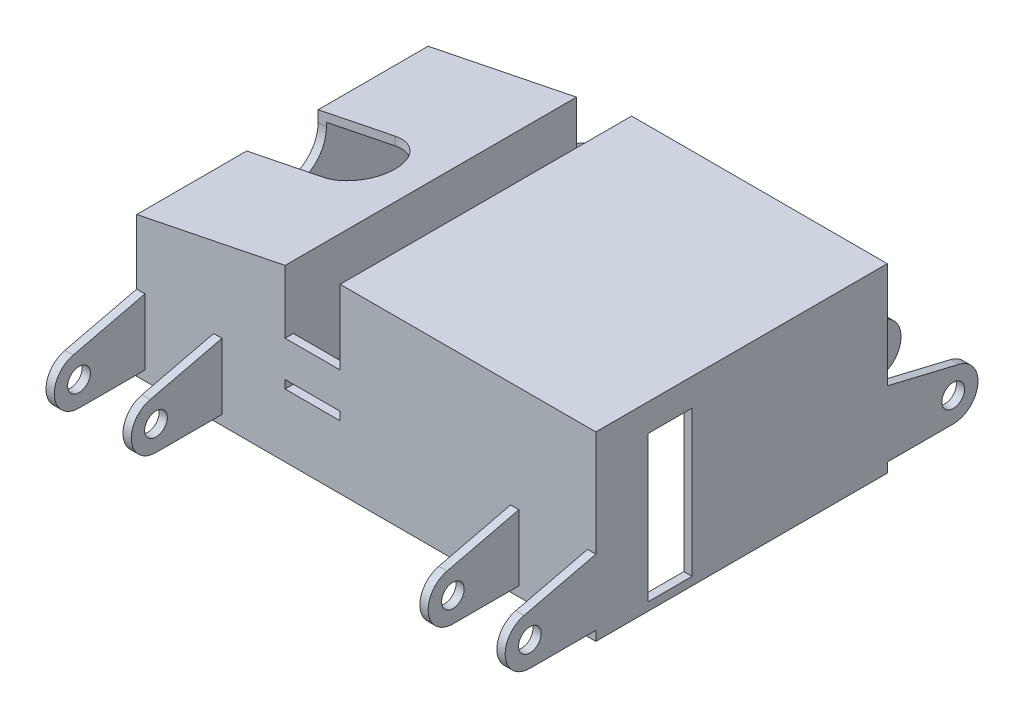
from build123d import *

# Parameters (mm, degrees)
BOSS_EXTRUDE1_DEPTH = 100
BOSS_EXTRUDE2_DEPTH = 3
SKETCH4_W           = 71
SKETCH4_H           = 3
BOSS_EXTRUDE3_DEPTH = 20
BOSS_EXTRUDE4_REACH = 48
SKETCH6_W           = 48
SKETCH6_H           = 3
CUT_EXTRUDE1_DEPTH  = 3
SKETCH8_R           = 2.5
SKETCH8_R_2         = 1.7
CUT_EXTRUDE2_DEPTH  = 3
SKETCH9_R           = 3.2
SKETCH9_R_2         = 2.5
CUT_EXTRUDE3_DEPTH  = 3
SKETCH10_R          = 1.7
CUT_EXTRUDE4_DEPTH  = 3
SKETCH13_R          = 2.5
CUT_EXTRUDE6_DEPTH  = 3
BOSS_EXTRUDE5_DEPTH = 3
BOSS_EXTRUDE6_DEPTH = 5
CUT_EXTRUDE8_DEPTH  = 18
SKETCH20_W          = 20.000898322
SKETCH20_H          = 3
CUT_EXTRUDE9_DEPTH  = 3
SKETCH21_W          = 20.000898322
SKETCH21_H          = 3
CUT_EXTRUDE10_DEPTH = 3
SKETCH22_R          = 4.125
BOSS_EXTRUDE7_DEPTH = 3
LPATTERN1_COUNT     = 2
LPATTERN1_PITCH     = 28
LPATTERN2_COUNT     = 2
LPATTERN2_PITCH     = 164
LPATTERN3_COUNT     = 2
LPATTERN3_PITCH     = 136
SKETCH23_W          = 16
SKETCH23_H          = 53
CUT_EXTRUDE11_DEPTH = 3


with BuildPart() as part:
    # Sketch1 → Boss-Extrude1 (new body)
    with BuildSketch(Plane.XY):
        Polygon((0, 60), (0, -3), (3, -3), (3, 63), (-90, 63), (-90, 20), (-110.000898322, 20), (-110.033128512, 58.939230707), (-164, 48), (-164, -3), (-161, -3), (-161, 45.547095944), (-113, 55.276825673), (-113, 17), (-90, 17), (-90, -3), (-87, -3), (-87, 60), align=None)
    extrude(amount=BOSS_EXTRUDE1_DEPTH)

    # Sketch2 → Boss-Extrude2 (add)
    with BuildSketch(Plane.XY.offset(100)):
        Polygon((-164, -3), (3, -3), (3, 63), (-90, 63), (-90, 35.999994519), (-110.014141595, 35.999994519), (-110.033128512, 58.939230707), (-164, 48), align=None)
    extrude(amount=BOSS_EXTRUDE2_DEPTH)

    # Sketch4 → Boss-Extrude3 (add)
    with BuildSketch(Plane.XZ.offset(3)):
        with Locations((-125.5, 67.5)):
            Rectangle(SKETCH4_W, SKETCH4_H)
    extrude(amount=-BOSS_EXTRUDE3_DEPTH)

    # Boss-Extrude4: up to this face of the body (flat: up to its plane)
    boss_extrude4_end = Plane(part.part.faces().sort_by_distance((-137, 50.411960808, 50))[0])
    # Sketch6 → Boss-Extrude4 (add, up to the picked face)
    with BuildSketch(Plane(origin=(0, 17, 0), x_dir=(1, 0, 0), z_dir=(0, 1, 0)), mode=Mode.PRIVATE) as boss_extrude4_sk1:
        with Locations((-137, -67.5)):
            Rectangle(SKETCH6_W, SKETCH6_H)
    boss_extrude4_tool1 = split(extrude(boss_extrude4_sk1.sketch, amount=BOSS_EXTRUDE4_REACH, mode=Mode.PRIVATE), bisect_by=boss_extrude4_end, keep=Keep.BOTH, mode=Mode.PRIVATE)
    add(boss_extrude4_tool1.solids().sort_by_distance((-137, 17, 67.5))[0])

    # Sketch7 → Cut-Extrude1 (cut)
    with BuildSketch(Plane.ZY.offset(164)):
        with BuildLine():
            Line((37, 44), (37, 57))
            Line((37, 57), (63, 57))
            Line((63, 57), (63, 44))
            ThreePointArc((63, 44), (50, 31), (37, 44))
        make_face()
    extrude(amount=-CUT_EXTRUDE1_DEPTH, mode=Mode.SUBTRACT)

    # Sketch8 → Cut-Extrude2 (cut)
    with BuildSketch(Plane(origin=(0, 0, 66), x_dir=(-1, 0, 0), z_dir=(0, 0, -1))):
        with Locations((136, 22)):
            Circle(SKETCH8_R)
        with Locations((151.5, 37.5)):
            Circle(SKETCH8_R_2)
        with Locations((120.5, 37.5)):
            Circle(SKETCH8_R_2)
        with Locations((151.5, 6.5)):
            Circle(SKETCH8_R_2)
        with Locations((120.5, 6.5)):
            Circle(SKETCH8_R_2)
    extrude(amount=-CUT_EXTRUDE2_DEPTH, mode=Mode.SUBTRACT)

    # Sketch9 → Cut-Extrude3 (cut)
    with BuildSketch(Plane(origin=(-87, 0, 0), x_dir=(0, 0, -1), z_dir=(1, 0, 0))):
        with Locations((-31, 29.5)):
            Circle(SKETCH9_R)
        with Locations((-7.43, 53.07)):
            Circle(SKETCH9_R_2)
        with Locations((-7.43, 5.93)):
            Circle(SKETCH9_R_2)
        with Locations((-54.57, 53.07)):
            Circle(SKETCH9_R_2)
        with Locations((-54.57, 5.93)):
            Circle(SKETCH9_R_2)
    extrude(amount=-CUT_EXTRUDE3_DEPTH, mode=Mode.SUBTRACT)

    # Sketch10 → Cut-Extrude4 (cut)
    with BuildSketch(Plane(origin=(0, 0, 66), x_dir=(-1, 0, 0), z_dir=(0, 0, -1))):
        with Locations((99.5, 6.5)):
            Circle(SKETCH10_R)
    extrude(amount=-CUT_EXTRUDE4_DEPTH, mode=Mode.SUBTRACT)

    # Sketch13 → Cut-Extrude6 (cut)
    with BuildSketch(Plane.ZY.offset(90)):
        with Locations((94.5, 6.43)):
            Circle(SKETCH13_R)
    extrude(amount=-CUT_EXTRUDE6_DEPTH, mode=Mode.SUBTRACT)

    # Sketch14 → Boss-Extrude5 (add)
    with BuildSketch(Plane(origin=(0, 0, 0), x_dir=(-1, 0, 0), z_dir=(0, 0, -1))):
        Polygon((-3, 63), (-3, -3), (164, -3), (164, 48), (110.033128512, 58.939230707), (110.014141595, 35.999994519), (90, 35.999994519), (90, 63), align=None)
    extrude(amount=BOSS_EXTRUDE5_DEPTH)

    # Sketch15 → Boss-Extrude6 (add)
    with BuildSketch(Plane.XZ.offset(3)):
        with BuildLine():
            ThreePointArc((-159, 93), (-155.464466094, 94.464466094), (-154, 98))
            Line((-154, 98), (-154, 100))
            Line((-154, 100), (-159, 100))
            ThreePointArc((-159, 100), (-157.585786438, 99.414213562), (-157, 98))
            ThreePointArc((-157, 98), (-159, 96), (-161, 98))
            Line((-161, 98), (-161, 93))
            Line((-161, 93), (-159, 93))
        make_face()
        with BuildLine():
            ThreePointArc((-161, 98), (-160.414213562, 99.414213562), (-159, 100))
            Line((-159, 100), (-161, 100))
            Line((-161, 100), (-161, 98))
        make_face()
        with BuildLine():
            Line((-7, 100), (-7, 98))
            ThreePointArc((-7, 98), (-5.535533906, 94.464466094), (-2, 93))
            Line((-2, 93), (0, 93))
            Line((0, 93), (0, 98))
            ThreePointArc((0, 98), (-3.414213563, 96.585786438), (-1.999999999, 100))
            Line((-1.999999999, 100), (-7, 100))
        make_face()
        with BuildLine():
            Line((0, 100), (-1.999999999, 100))
            ThreePointArc((-1.999999999, 100), (-0.585786437, 99.414213562), (0, 98))
            Line((0, 98), (0, 100))
        make_face()
        with BuildLine():
            Line((0, 2), (0, 7))
            Line((0, 7), (-2, 7))
            ThreePointArc((-2, 7), (-5.535533906, 5.535533906), (-7, 2))
            Line((-7, 2), (-7, 0))
            Line((-7, 0), (-2, 0))
            ThreePointArc((-2, 0), (-3.414213562, 3.414213562), (0, 2))
        make_face()
        with BuildLine():
            Line((0, 0), (0, 2))
            ThreePointArc((0, 2), (-0.585786438, 0.585786438), (-2, 0))
            Line((-2, 0), (0, 0))
        make_face()
        with BuildLine():
            ThreePointArc((-154, 2), (-155.464466094, 5.535533906), (-159, 7))
            Line((-159, 7), (-161, 7))
            Line((-161, 7), (-161, 2))
            ThreePointArc((-161, 2), (-159, 4), (-157, 2))
            ThreePointArc((-157, 2), (-157.585786438, 0.585786438), (-159, 0))
            Line((-159, 0), (-154, 0))
            Line((-154, 0), (-154, 2))
        make_face()
        with BuildLine():
            ThreePointArc((-159, 0), (-160.414213562, 0.585786438), (-161, 2))
            Line((-161, 2), (-161, 0))
            Line((-161, 0), (-159, 0))
        make_face()
    extrude(amount=-BOSS_EXTRUDE6_DEPTH)

    # Sketch19 → Cut-Extrude8 (cut)
    with BuildSketch(Plane(origin=(0, 63, 0), x_dir=(1, 0, 0), z_dir=(0, 1, 0))):
        with BuildLine():
            Line((-136, -37), (-164, -37))
            Line((-164, -37), (-164, -63))
            Line((-164, -63), (-136, -63))
            ThreePointArc((-136, -63), (-123, -50), (-136, -37))
        make_face()
    extrude(amount=-CUT_EXTRUDE8_DEPTH, mode=Mode.SUBTRACT)

    # Sketch20 → Cut-Extrude9 (cut)
    with BuildSketch(Plane(origin=(0, 0, 100), x_dir=(-1, 0, 0), z_dir=(0, 0, -1))):
        with Locations((100.000449161, 21.5)):
            Rectangle(SKETCH20_W, SKETCH20_H)
    extrude(amount=-CUT_EXTRUDE9_DEPTH, mode=Mode.SUBTRACT)

    # Sketch21 → Cut-Extrude10 (cut)
    with BuildSketch(Plane.XY):
        with Locations((-100.000449161, 21.5)):
            Rectangle(SKETCH21_W, SKETCH21_H)
    extrude(amount=-CUT_EXTRUDE10_DEPTH, mode=Mode.SUBTRACT)

    # Sketch22 → Boss-Extrude7 (add)
    with BuildSketch(Plane.ZY.offset(164)):
        with BuildLine():
            Line((103, 0.500009795), (103, 24.5))
            Line((103, 24.5), (129.095417441, 18.252679991))
            ThreePointArc((129.095417441, 18.252679991), (135.937956019, 8.445029172), (127.000002345, 0.500009795))
            Line((127.000002345, 0.500009795), (103, 0.500009795))
        make_face()
        with Locations((127.000002345, 9.500009795)):
            Circle(SKETCH22_R, mode=Mode.SUBTRACT)
        with BuildLine():
            Line((-3, 24.5), (-29.095417441, 18.252679991))
            ThreePointArc((-29.095417441, 18.252679991), (-35.937956019, 8.445029172), (-27.000002345, 0.500009795))
            Line((-27.000002345, 0.500009795), (-3, 0.500009795))
            Line((-3, 0.500009795), (-3, 24.5))
        make_face()
        with Locations((-27.000002345, 9.500009795)):
            Circle(SKETCH22_R, mode=Mode.SUBTRACT)
    boss_extrude7 = extrude(amount=-BOSS_EXTRUDE7_DEPTH)

    # LPattern1: Boss-Extrude7 ×2
    with Locations(*[(i * LPATTERN1_PITCH, 0, 0) for i in range(1, LPATTERN1_COUNT)]):
        add(boss_extrude7)

    # LPattern2: Boss-Extrude7 ×2
    with Locations(*[(i * LPATTERN2_PITCH, 0, 0) for i in range(1, LPATTERN2_COUNT)]):
        add(boss_extrude7)

    # LPattern3: Boss-Extrude7 ×2
    with Locations(*[(i * LPATTERN3_PITCH, 0, 0) for i in range(1, LPATTERN3_COUNT)]):
        add(boss_extrude7)

    # Sketch23 → Cut-Extrude11 (cut)
    with BuildSketch(Plane(origin=(3, 0, 0), x_dir=(0, 0, -1), z_dir=(1, 0, 0))):
        with Locations((-76, 26.5)):
            Rectangle(SKETCH23_W, SKETCH23_H)
    extrude(amount=-CUT_EXTRUDE11_DEPTH, mode=Mode.SUBTRACT)


solid = part.part
